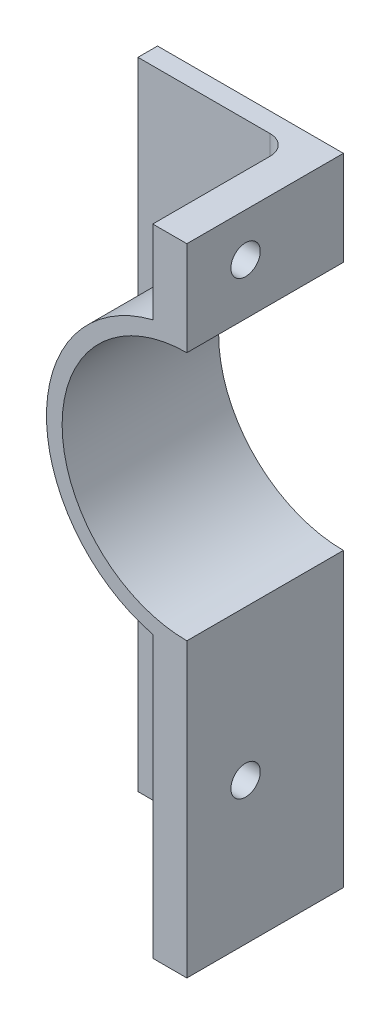
from build123d import *

# Parameters (mm, degrees)
BOSS_EXTRUDE5_DEPTH     = 20.32
BOSS_EXTRUDE6_DEPTH     = 2.54
CUT_EXTRUDE3_DEPTH      = 89.372290906
CUT_EXTRUDE3_DEPTH_BACK = 89.372290906
SKETCH3_R               = 1.905
FILLET3_R               = 2.54


with BuildPart() as part:
    # Sketch2 → Boss-Extrude5 (new body)
    with BuildSketch(Plane.XY):
        with BuildLine():
            Line((19.702242383, 36.423556552), (19.702242383, 0))
            Line((19.702242383, 0), (24.13, 0))
            Line((24.13, 0), (24.13, 37.9095))
            ThreePointArc((24.13, 37.9095), (7.9375, 54.102), (24.13, 70.2945))
            Line((24.13, 70.2945), (24.13, 82.55))
            Line((24.13, 82.55), (19.702242383, 82.55))
            Line((19.702242383, 82.55), (19.702242383, 71.780443448))
            ThreePointArc((19.702242383, 71.780443448), (5.9055, 54.102), (19.702242383, 36.423556552))
        make_face()
    extrude(amount=BOSS_EXTRUDE5_DEPTH)

    # Sketch2_7 → Boss-Extrude6 (add)
    with BuildSketch(Plane.XY):
        with BuildLine():
            Line((0, 82.55), (0, 0))
            Line((0, 0), (19.702242383, 0))
            Line((19.702242383, 0), (19.702242383, 36.423556552))
            ThreePointArc((19.702242383, 36.423556552), (5.9055, 54.102), (19.702242383, 71.780443448))
            Line((19.702242383, 71.780443448), (19.702242383, 82.55))
            Line((19.702242383, 82.55), (0, 82.55))
        make_face()
    extrude(amount=BOSS_EXTRUDE6_DEPTH)

    # Sketch3 → Cut-Extrude3 (cut, two sides: drawn at the far end of the back side and taken through both)
    with BuildSketch(Plane(origin=(0, 0, 0), x_dir=(0, 0, -1), z_dir=(1, 0, 0)).offset(-CUT_EXTRUDE3_DEPTH_BACK)):
        with Locations((-12.7, 18.430889618)):
            Circle(SKETCH3_R)
        with Locations((-12.7, 76.946110382)):
            Circle(SKETCH3_R)
    extrude(amount=CUT_EXTRUDE3_DEPTH + CUT_EXTRUDE3_DEPTH_BACK, mode=Mode.SUBTRACT)

    # Fillet3
    fillet3_edges = [part.edges().sort_by_distance(p)[0] for p in [
        (19.702242383, 77.165221724, 2.54),
        (5.9055, 54.102, 2.54),
        (19.702242383, 18.211778276, 2.54),
    ]]
    fillet(fillet3_edges, radius=FILLET3_R)


solid = part.part
